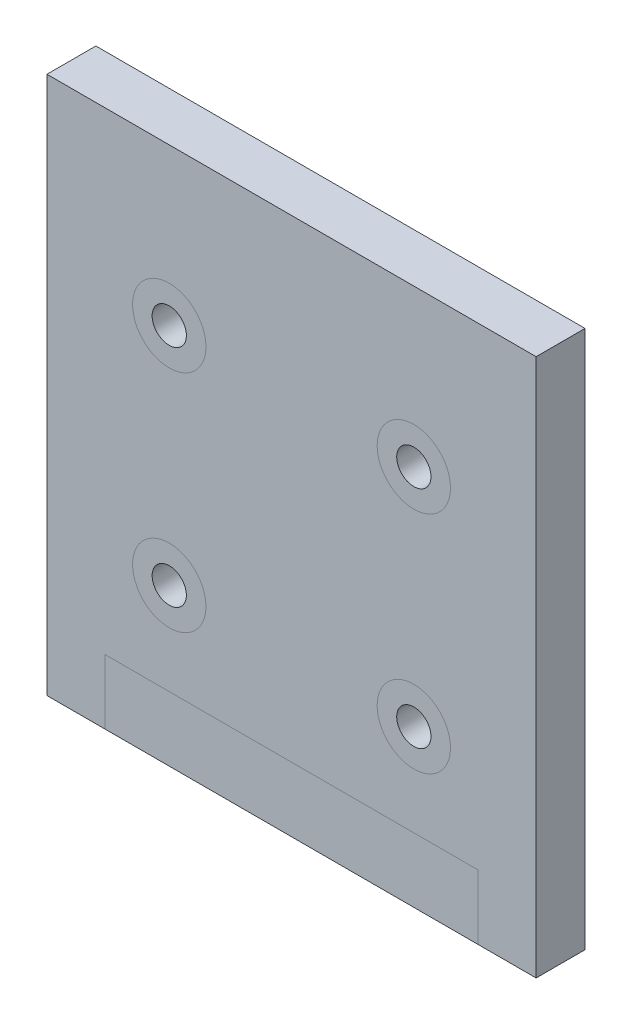
from build123d import *

# Parameters (mm, degrees)
SKETCH1_W      = 127
SKETCH1_H      = 139.7
SKETCH1_R      = 4.445
EXTRUDE1_DEPTH = 12.7


with BuildPart() as part:
    # Sketch1 → Extrude1 (new body)
    with BuildSketch(Plane.XY):
        with Locations((63.5, 69.85)):
            Rectangle(SKETCH1_W, SKETCH1_H)
        with Locations((31.75, 40.64)):
            Circle(SKETCH1_R, mode=Mode.SUBTRACT)
        with Locations((95.25, 40.64)):
            Circle(SKETCH1_R, mode=Mode.SUBTRACT)
        with Locations((31.75, 99.06)):
            Circle(SKETCH1_R, mode=Mode.SUBTRACT)
        with Locations((95.25, 99.06)):
            Circle(SKETCH1_R, mode=Mode.SUBTRACT)
    extrude(amount=EXTRUDE1_DEPTH)


solid = part.part
